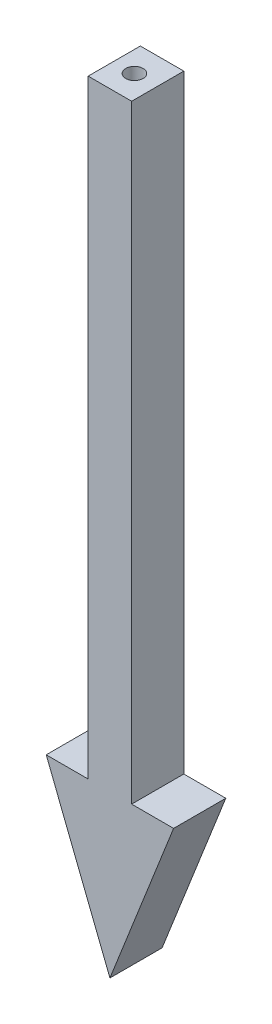
from build123d import *

# Parameters (mm, degrees)
BOSS_EXTRUDE1_DEPTH = 12
SKETCH2_R           = 2
CUT_EXTRUDE1_DEPTH  = 10


with BuildPart() as part:
    # Sketch1 → Boss-Extrude1 (new body)
    with BuildSketch(Plane.XY):
        Polygon((-9.541165506, 105.498159978), (-9.541165506, 95.498159978), (-9.541165506, -34.501840022), (-19.192936941, -34.501840022), (-4.541165506, -71.632080767), (10.110605928, -34.501840022), (0.458834494, -34.501840022), (0.458834494, 95.498159978), (0.458834494, 105.498159978), align=None)
    extrude(amount=BOSS_EXTRUDE1_DEPTH)

    # Sketch2 → Cut-Extrude1 (cut)
    with BuildSketch(Plane(origin=(0, 105.498159978, 0), x_dir=(1, 0, 0), z_dir=(0, 1, 0))):
        with Locations((-4.745886353, -6.153540635)):
            Circle(SKETCH2_R)
    extrude(amount=-CUT_EXTRUDE1_DEPTH, mode=Mode.SUBTRACT)


solid = part.part
